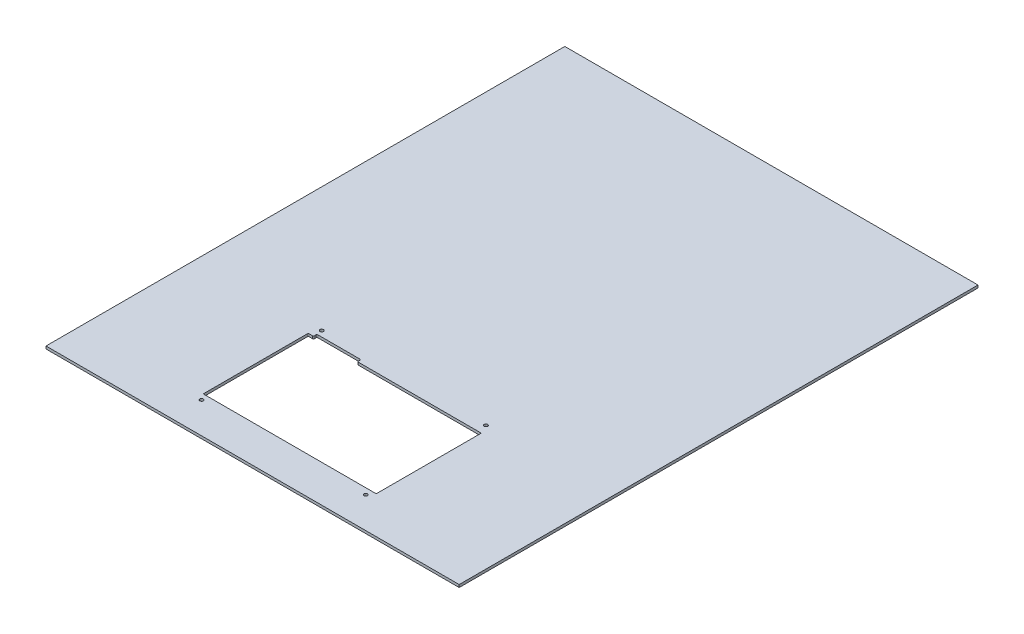
from build123d import *

# Parameters (mm, degrees)
SKETCH1_W           = 395
SKETCH1_H           = 496
BOSS_EXTRUDE1_DEPTH = 2.5
CUT_EXTRUDE1_DEPTH  = 2.5
SKETCH6_R           = 1.65
CUT_EXTRUDE2_DEPTH  = 2.5


with BuildPart() as part:
    # Sketch1 → Boss-Extrude1 (new body)
    with BuildSketch(Plane(origin=(0, 0, 0), x_dir=(1, 0, 0), z_dir=(0, 1, 0))):
        Rectangle(SKETCH1_W, SKETCH1_H)
    extrude(amount=BOSS_EXTRUDE1_DEPTH)

    # Sketch4 → Cut-Extrude1 (cut)
    with BuildSketch(Plane(origin=(0, 2.5, 0), x_dir=(1, 0, 0), z_dir=(0, 1, 0))):
        with BuildLine():
            Line((-78.7, -112.1), (-82.2, -112.1))
            ThreePointArc((-82.2, -112.1), (-82.553553391, -112.246446609), (-82.7, -112.6))
            Line((-82.7, -112.6), (-82.7, -212))
            ThreePointArc((-82.7, -212), (-82.553553391, -212.353553391), (-82.2, -212.5))
            Line((-82.2, -212.5), (82.2, -212.5))
            ThreePointArc((82.2, -212.5), (82.553553391, -212.353553391), (82.7, -212))
            Line((82.7, -212), (82.7, -112.6))
            ThreePointArc((82.7, -112.6), (82.553553391, -112.246446609), (82.2, -112.1))
            Line((82.2, -112.1), (-34.7, -112.1))
            ThreePointArc((-34.7, -112.1), (-35.407106781, -111.807106781), (-35.7, -111.1))
            Line((-35.7, -111.1), (-35.7, -109.8))
            ThreePointArc((-35.7, -109.8), (-35.992893219, -109.092893219), (-36.7, -108.8))
            Line((-36.7, -108.8), (-76.7, -108.8))
            ThreePointArc((-76.7, -108.8), (-77.407106781, -109.092893219), (-77.7, -109.8))
            Line((-77.7, -109.8), (-77.7, -111.1))
            ThreePointArc((-77.7, -111.1), (-77.992893219, -111.807106781), (-78.7, -112.1))
        make_face()
    extrude(amount=-CUT_EXTRUDE1_DEPTH, mode=Mode.SUBTRACT)

    # Sketch6 → Cut-Extrude2 (cut)
    with BuildSketch(Plane(origin=(0, 2.5, 0), x_dir=(1, 0, 0), z_dir=(0, 1, 0))):
        with Locations((78.5, -103.4)):
            Circle(SKETCH6_R)
        with Locations((-78.5, -103.4)):
            Circle(SKETCH6_R)
        with Locations((-78.5, -218.3)):
            Circle(SKETCH6_R)
        with Locations((78.5, -218.3)):
            Circle(SKETCH6_R)
    extrude(amount=-CUT_EXTRUDE2_DEPTH, mode=Mode.SUBTRACT)


solid = part.part
